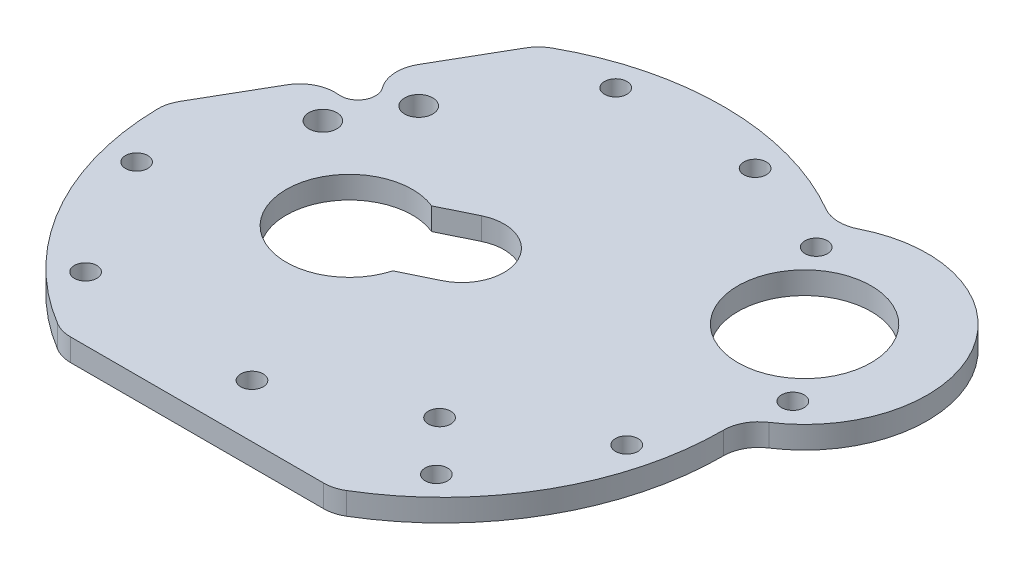
from build123d import *

# Parameters (mm, degrees)
SKETCH2_R           = 9.5
SKETCH2_R_2         = 1.599999999
BOSS_EXTRUDE1_DEPTH = 3.175
FILLET1_R           = 5
CUT_EXTRUDE1_REACH  = 5.175
SKETCH3_R           = 2
FILLET2_R           = 5


with BuildPart() as part:
    # Sketch2 → Boss-Extrude1 (new body)
    with BuildSketch(Plane(origin=(0, 0, 0), x_dir=(1, 0, 0), z_dir=(0, 1, 0))):
        with BuildLine():
            Line((-20.628430767, 34.270509831), (-39.993347498, 0.729490169))
            ThreePointArc((-39.993347498, 0.729490169), (-34.641016151, -20), (-19.364916731, -35))
            Line((-19.364916731, -35), (19.364916731, -35))
            ThreePointArc((19.364916731, -35), (35.177698311, -19.040208548), (39.892817403, 2.92628085))
            ThreePointArc((39.892817403, 2.92628085), (47.858623368, 27.631189084), (22.480642256, 33.085052875))
            ThreePointArc((22.480642256, 33.085052875), (1.09954486, 39.984884658), (-20.628430767, 34.270509831))
        make_face()
        with Locations((32.703178801, 18.881189084)):
            Circle(SKETCH2_R, mode=Mode.SUBTRACT)
        with Locations((-9.933234274, 34.602468942)):
            Circle(SKETCH2_R_2, mode=Mode.SUBTRACT)
        with Locations((34.933234274, -8.698801248)):
            Circle(SKETCH2_R_2, mode=Mode.SUBTRACT)
        with Locations((24.025546071, 29.222789066)):
            Circle(SKETCH2_R_2, mode=Mode.SUBTRACT)
        with Locations((41.380811532, 8.539589102)):
            Circle(SKETCH2_R_2, mode=Mode.SUBTRACT)
        with Locations((9.933234274, 34.602468942)):
            Circle(SKETCH2_R_2, mode=Mode.SUBTRACT)
        with Locations((18.218514563, -18.662886757)):
            Circle(SKETCH2_R_2, mode=Mode.SUBTRACT)
        with Locations((-25, -25.903667694)):
            Circle(SKETCH2_R_2, mode=Mode.SUBTRACT)
        with Locations((0.242633637, -27.430309692)):
            Circle(SKETCH2_R_2, mode=Mode.SUBTRACT)
        with Locations((25, -25.903667694)):
            Circle(SKETCH2_R_2, mode=Mode.SUBTRACT)
        with Locations((-34.933234274, -8.698801248)):
            Circle(SKETCH2_R_2, mode=Mode.SUBTRACT)
        with BuildLine():
            Line((-3.733919578, 9.237483049), (-8.490154378, 6.917712338))
            ThreePointArc((-8.490154378, 6.917712338), (-19.978367669, -5.361075311), (-3.229700616, -3.867816217))
            Line((-3.229700616, -3.867816217), (1.526534184, -1.548045507))
            ThreePointArc((1.526534184, -1.548045507), (4.289071581, 6.474945652), (-3.733919578, 9.237483049))
        make_face(mode=Mode.SUBTRACT)
    extrude(amount=BOSS_EXTRUDE1_DEPTH)

    # Fillet1
    fillet1_edges = [part.edges().sort_by_distance(p)[0] for p in [
        (39.892817403, 1.5875, -2.92628085),
        (22.480642256, 1.5875, -33.085052875),
    ]]
    fillet(fillet1_edges, radius=FILLET1_R)

    # Sketch3 → Cut-Extrude1 (cut, up to next)
    with BuildSketch(Plane(origin=(0, 3.175, 0), x_dir=(1, 0, 0), z_dir=(0, 1, 0)), mode=Mode.PRIVATE) as cut_extrude1_sk1:
        with Locations((-26.748711306, 9.669872981)):
            Circle(SKETCH3_R)
    cut_extrude1_tool1 = extrude(cut_extrude1_sk1.sketch, amount=-CUT_EXTRUDE1_REACH, mode=Mode.PRIVATE) & part.part
    add(cut_extrude1_tool1.solids().sort_by_distance((-26.748711, 3.175, -9.669873))[0], mode=Mode.SUBTRACT)
    # Sketch3 → Cut-Extrude1 (cut, up to next)
    with BuildSketch(Plane(origin=(0, 3.175, 0), x_dir=(1, 0, 0), z_dir=(0, 1, 0)), mode=Mode.PRIVATE) as cut_extrude1_sk2:
        with Locations((-21.748711306, 18.330127019)):
            Circle(SKETCH3_R)
    cut_extrude1_tool2 = extrude(cut_extrude1_sk2.sketch, amount=-CUT_EXTRUDE1_REACH, mode=Mode.PRIVATE) & part.part
    add(cut_extrude1_tool2.solids().sort_by_distance((-21.748711, 3.175, -18.330127))[0], mode=Mode.SUBTRACT)
    # Sketch3 → Cut-Extrude1 (cut, up to next)
    with BuildSketch(Plane(origin=(0, 3.175, 0), x_dir=(1, 0, 0), z_dir=(0, 1, 0)), mode=Mode.PRIVATE) as cut_extrude1_sk3:
        with BuildLine():
            Line((-29.060889132, 19.665063509), (-27.328838325, 18.665063509))
            ThreePointArc((-27.328838325, 18.665063509), (-26.413774815, 15.25), (-29.828838325, 14.334936491))
            Line((-29.828838325, 14.334936491), (-31.560889132, 15.334936491))
            ThreePointArc((-31.560889132, 15.334936491), (-32.475952642, 18.75), (-29.060889132, 19.665063509))
        make_face()
    cut_extrude1_tool3 = extrude(cut_extrude1_sk3.sketch, amount=-CUT_EXTRUDE1_REACH, mode=Mode.PRIVATE) & part.part
    add(cut_extrude1_tool3.solids().sort_by_distance((-29.444864, 3.175, -17))[0], mode=Mode.SUBTRACT)

    # Fillet2
    fillet2_edges = [part.edges().sort_by_distance(p)[0] for p in [
        (-31.560889132, 1.5875, -15.334936491),
        (-29.060889132, 1.5875, -19.665063509),
        (19.364916731, 1.5875, 35),
        (-19.364916731, 1.5875, 35),
        (-39.993347498, 1.5875, -0.729490169),
        (-20.628430767, 1.5875, -34.270509831),
    ]]
    fillet(fillet2_edges, radius=FILLET2_R)


solid = part.part
